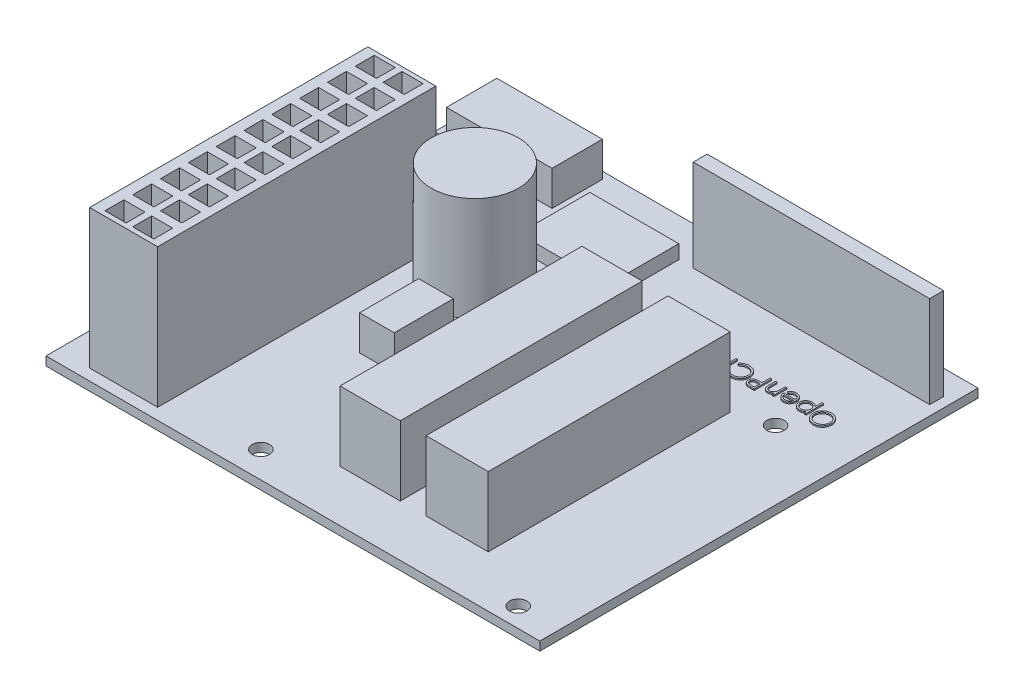
from build123d import *

# Parameters (mm, degrees)
SKETCH4_W                                   = 90.17
SKETCH4_H                                   = 80.01
PCB_DEPTH                                   = 1.6002
SKETCH18_W                                  = 12.407886853
SKETCH18_H                                  = 50.8
ATX_PLUG_DEPTH                              = 25.4
SKETCH19_W                                  = 19.276255561
SKETCH19_H                                  = 9.196610238
TERMINAL_BLOCK_PELTIER_LID_HEATER_LID_DEPTH = 6.35
SKETCH20_W                                  = 43.18
SKETCH20_H                                  = 2.54
LCD_RIBBON_HEADERS_DEPTH                    = 16.764
SKETCH21_W                                  = 9.458667613
SKETCH21_H                                  = 6.032312137
F_2_PIN_BLOCK_THERMISTOR_PLUG_DEPTH         = 6.35
SKETCH23_W                                  = 6.335830851
SKETCH23_H                                  = 10.787396263
F_3_PIN_FAN_PLUG_DEPTH                      = 6.35
SKETCH26_R                                  = 7.964425937
BOSS_EXTRUDE1_DEPTH                         = 19.05
SKETCH27_W                                  = 11.001790229
SKETCH27_H                                  = 44.181792507
SKETCH27_W_2                                = 11.351053411
BOSS_EXTRUDE2_DEPTH                         = 12.7
SKETCH28_W                                  = 16.235615253
SKETCH28_H                                  = 12.988492202
BOSS_EXTRUDE3_DEPTH                         = 2.54
SKETCH29_W                                  = 3.855958623
SKETCH29_H                                  = 3.450068241
CUT_EXTRUDE1_DEPTH                          = 12.7
BOSS_EXTRUDE4_DEPTH                         = 0.254
SKETCH36_R                                  = 0.508
BOSS_EXTRUDE8_DEPTH                         = 6.35
SKETCH25_W                                  = 2.54
SKETCH25_H                                  = 43.749294164
SKETCH25_H_2                                = 32.765794335
EXTRUSION_FOR_HEADERS_DEPTH                 = 2.54
ARDUINO_HOLES_REACH                         = 9.95
SKETCH39_R                                  = 1.5875


with BuildPart() as part:
    # Sketch4 → PCB (new body)
    with BuildSketch(Plane(origin=(0, 0, 0), x_dir=(1, 0, 0), z_dir=(0, 1, 0))):
        with Locations((-77.667503466, -6.362850239)):
            Rectangle(SKETCH4_W, SKETCH4_H)
    extrude(amount=PCB_DEPTH)

    # Sketch18 → ATX plug (add)
    with BuildSketch(Plane(origin=(0, 1.6002, 0), x_dir=(1, 0, 0), z_dir=(0, 1, 0))):
        with Locations((-110.63442677, -18.903310009)):
            Rectangle(SKETCH18_W, SKETCH18_H)
    extrude(amount=ATX_PLUG_DEPTH)

    # Sketch19 → Terminal block (peltier, lid heater, lid thermistor) (add)
    with BuildSketch(Plane(origin=(0, 1.6002, 0), x_dir=(1, 0, 0), z_dir=(0, 1, 0))):
        with Locations((-109.512826264, 27.756447705)):
            Rectangle(SKETCH19_W, SKETCH19_H)
    extrude(amount=TERMINAL_BLOCK_PELTIER_LID_HEATER_LID_DEPTH)

    # Sketch20 → LCD ribbon headers (add)
    with BuildSketch(Plane(origin=(0, 1.6002, 0), x_dir=(1, 0, 0), z_dir=(0, 1, 0))):
        with Locations((-55.96072751, 27.878210827)):
            Rectangle(SKETCH20_W, SKETCH20_H)
    extrude(amount=LCD_RIBBON_HEADERS_DEPTH)

    # Sketch21 → 2 pin block thermistor plug (add)
    with BuildSketch(Plane(origin=(0, 1.6002, 0), x_dir=(1, 0, 0), z_dir=(0, 1, 0))):
        with Locations((-114.2222126, 15.215258359)):
            Rectangle(SKETCH21_W, SKETCH21_H)
    extrude(amount=F_2_PIN_BLOCK_THERMISTOR_PLUG_DEPTH)

    # Sketch23 → 3 pin Fan plug (add)
    with BuildSketch(Plane(origin=(0, 1.6002, 0), x_dir=(1, 0, 0), z_dir=(0, 1, 0))):
        with Locations((-91.430208101, -11.865553383)):
            Rectangle(SKETCH23_W, SKETCH23_H)
    extrude(amount=F_3_PIN_FAN_PLUG_DEPTH)

    # Sketch26 → Boss-Extrude1 (add)
    with BuildSketch(Plane(origin=(0, 1.6002, 0), x_dir=(1, 0, 0), z_dir=(0, 1, 0))):
        with Locations((-95.051794494, 4.239066683)):
            Circle(SKETCH26_R)
    extrude(amount=BOSS_EXTRUDE1_DEPTH)

    # Sketch27 → Boss-Extrude2 (add)
    with BuildSketch(Plane(origin=(0, 1.6002, 0), x_dir=(1, 0, 0), z_dir=(0, 1, 0))):
        with Locations((-72.960898241, -14.883092526)):
            Rectangle(SKETCH27_W, SKETCH27_H)
        with Locations((-57.069423466, -14.883092526)):
            Rectangle(SKETCH27_W_2, SKETCH27_H)
    extrude(amount=BOSS_EXTRUDE2_DEPTH)

    # Sketch28 → Boss-Extrude3 (add)
    with BuildSketch(Plane(origin=(0, 1.6002, 0), x_dir=(1, 0, 0), z_dir=(0, 1, 0))):
        with Locations((-88.306822616, 20.113964726)):
            Rectangle(SKETCH28_W, SKETCH28_H)
    extrude(amount=BOSS_EXTRUDE3_DEPTH)

    # Sketch29 → Cut-Extrude1 (cut)
    with BuildSketch(Plane(origin=(0, 27.0002, 0), x_dir=(1, 0, 0), z_dir=(0, 1, 0))):
        with Locations((-107.913672572, 4.004968545)):
            Rectangle(SKETCH29_W, SKETCH29_H)
        with Locations((-112.993672572, 4.004968545)):
            Rectangle(SKETCH29_W, SKETCH29_H)
        with Locations((-112.993672572, -1.075031456)):
            Rectangle(SKETCH29_W, SKETCH29_H)
        with Locations((-107.913672572, -1.075031456)):
            Rectangle(SKETCH29_W, SKETCH29_H)
        with Locations((-112.993672572, -6.155031456)):
            Rectangle(SKETCH29_W, SKETCH29_H)
        with Locations((-107.913672572, -6.155031456)):
            Rectangle(SKETCH29_W, SKETCH29_H)
        with Locations((-112.993672572, -11.235031456)):
            Rectangle(SKETCH29_W, SKETCH29_H)
        with Locations((-107.913672572, -11.235031456)):
            Rectangle(SKETCH29_W, SKETCH29_H)
        with Locations((-112.993672572, -16.315031456)):
            Rectangle(SKETCH29_W, SKETCH29_H)
        with Locations((-107.913672572, -16.315031456)):
            Rectangle(SKETCH29_W, SKETCH29_H)
        with Locations((-112.993672572, -21.395031456)):
            Rectangle(SKETCH29_W, SKETCH29_H)
        with Locations((-107.913672572, -21.395031456)):
            Rectangle(SKETCH29_W, SKETCH29_H)
        with Locations((-112.993672572, -26.475031456)):
            Rectangle(SKETCH29_W, SKETCH29_H)
        with Locations((-107.913672572, -26.475031456)):
            Rectangle(SKETCH29_W, SKETCH29_H)
        with Locations((-112.993672572, -31.555031456)):
            Rectangle(SKETCH29_W, SKETCH29_H)
        with Locations((-107.913672572, -31.555031456)):
            Rectangle(SKETCH29_W, SKETCH29_H)
        with Locations((-112.993672572, -36.635031455)):
            Rectangle(SKETCH29_W, SKETCH29_H)
        with Locations((-107.913672572, -36.635031455)):
            Rectangle(SKETCH29_W, SKETCH29_H)
        with Locations((-112.993672572, -41.715031456)):
            Rectangle(SKETCH29_W, SKETCH29_H)
        with Locations((-107.913672572, -41.715031456)):
            Rectangle(SKETCH29_W, SKETCH29_H)
    extrude(amount=-CUT_EXTRUDE1_DEPTH, mode=Mode.SUBTRACT)

    # Sketch30 → Boss-Extrude4 (add)
    with BuildSketch(Plane(origin=(0, 1.6002, 0), x_dir=(-1, 0, 0), z_dir=(0, 1, 0))):
        with BuildLine():
            add(Edge.make_bspline(
                [(41.726381615, -12.7340868), (41.785171825, -12.735575856), (41.900640648, -12.738500485), (42.070344306, -12.760887958), (42.232355571, -12.799618776), (42.387994197, -12.851201624), (42.53539854, -12.920012388), (42.675678106, -13.003183915), (42.808499128, -13.10158756), (42.932071381, -13.214462645), (43.045153043, -13.337274778), (43.144780811, -13.468336882), (43.228276321, -13.60685651), (43.296843427, -13.752417406), (43.350635738, -13.904690377), (43.387755156, -14.064487222), (43.411466192, -14.230772577), (43.414238219, -14.344189804), (43.415644435, -14.401725021)],
                knots=[0, 0, 0, 0, 0.000176342, 0.00034635, 0.000512345, 0.00067546, 0.000837376, 0.000999356, 0.00116396, 0.001332355, 0.001500709, 0.001664166, 0.001825381, 0.001984993, 0.002146116, 0.00230887, 0.002476442, 0.002648971, 0.002648971, 0.002648971, 0.002648971], degree=3))
            add(Edge.make_bspline(
                [(43.415644435, -14.401725021), (43.414238425, -14.458836418), (43.411467016, -14.5714096), (43.387728196, -14.736639724), (43.350498146, -14.895471999), (43.297342962, -15.04764127), (43.229102706, -15.19330806), (43.14505123, -15.332089082), (43.04604456, -15.464029834), (42.933371202, -15.587684895), (42.810543114, -15.701075457), (42.678798515, -15.799880438), (42.541100289, -15.884901608), (42.395676482, -15.952741083), (42.244455735, -16.006962754), (42.086084627, -16.043931211), (41.921305253, -16.067777315), (41.808936557, -16.07051554), (41.75182232, -16.071907312)],
                knots=[0, 0, 0, 0, 0.000171259, 0.000337571, 0.000499706, 0.000660019, 0.000820206, 0.000981421, 0.001145895, 0.001314289, 0.001482643, 0.001646609, 0.00180761, 0.001967222, 0.002127146, 0.002288662, 0.002454344, 0.002625603, 0.002625603, 0.002625603, 0.002625603], degree=3))
            add(Edge.make_bspline(
                [(41.75182232, -16.071907312), (41.694287402, -16.070501797), (41.580870763, -16.067731152), (41.414376452, -16.043980878), (41.254467356, -16.006841267), (41.101600766, -15.95376485), (40.955691437, -15.885169219), (40.816454005, -15.801526675), (40.68444735, -15.702278768), (40.560765908, -15.589641947), (40.447600564, -15.467022039), (40.348940274, -15.335636679), (40.265278921, -15.198063515), (40.196913612, -15.053920761), (40.142789424, -14.903905238), (40.105864339, -14.747016262), (40.081973868, -14.584148282), (40.079220829, -14.47325651), (40.077823922, -14.416989444)],
                knots=[0, 0, 0, 0, 0.00017253, 0.000340102, 0.000503474, 0.000664388, 0.000824575, 0.000986335, 0.001150809, 0.001319204, 0.001487557, 0.001650632, 0.001811303, 0.001969765, 0.00212849, 0.002288769, 0.002452562, 0.00262128, 0.00262128, 0.00262128, 0.00262128], degree=3))
            add(Edge.make_bspline(
                [(40.077823922, -14.416989444), (40.078308913, -14.379222665), (40.079272776, -14.304165553), (40.090876669, -14.192707995), (40.107714783, -14.083042898), (40.131846518, -13.975482109), (40.16340753, -13.87028893), (40.200647584, -13.766737881), (40.246131586, -13.66587836), (40.297549031, -13.567232569), (40.354936529, -13.472338255), (40.418323816, -13.382640347), (40.485484471, -13.297386157), (40.559111264, -13.218784947), (40.636777611, -13.14455013), (40.719743425, -13.075822522), (40.807502461, -13.011982388), (40.900432334, -12.954451079), (40.996243198, -12.902418149), (41.095009989, -12.857766899), (41.195391308, -12.819443686), (41.29785731, -12.788382366), (41.402135896, -12.763860448), (41.508454658, -12.747162348), (41.616728894, -12.73552886), (41.689673448, -12.734569554), (41.726381615, -12.7340868)],
                knots=[0, 0, 0, 0, 0.000113256, 0.000225083, 0.000335817, 0.000445988, 0.000555461, 0.000665116, 0.000775867, 0.0008871, 0.000998686, 0.001108262, 0.001216432, 0.001323994, 0.001431064, 0.001538557, 0.001646949, 0.001756368, 0.001866213, 0.001973803, 0.002081296, 0.002188332, 0.002294783, 0.002402377, 0.00251104, 0.002621117, 0.002621117, 0.002621117, 0.002621117], degree=3))
        make_face()
        with BuildLine():
            add(Edge.make_bspline(
                [(41.740374002, -13.059727825), (41.710243585, -13.060095118), (41.650270798, -13.060826194), (41.561112683, -13.070456164), (41.473127143, -13.084181135), (41.386296008, -13.103758657), (41.300982588, -13.130432334), (41.216391661, -13.161130872), (41.133294605, -13.19852429), (41.051965748, -13.240772386), (40.973121358, -13.287534621), (40.898724122, -13.339216153), (40.828581438, -13.394604984), (40.762865046, -13.453830379), (40.701767911, -13.517193947), (40.644087504, -13.583735085), (40.592135812, -13.655355729), (40.544523895, -13.730113741), (40.501917355, -13.807911747), (40.464030211, -13.887930694), (40.433038575, -13.970823309), (40.407763419, -14.055690295), (40.386808591, -14.142397241), (40.373533531, -14.231601904), (40.363797748, -14.322856041), (40.36310846, -14.384525294), (40.36275982, -14.415717408)],
                knots=[0, 0, 0, 0, 9.035e-05, 0.000179837, 0.000268716, 0.000357433, 0.000446559, 0.000536708, 0.000627246, 0.000719699, 0.000811541, 0.000902048, 0.000991247, 0.001079509, 0.001167217, 0.001255174, 0.001343459, 0.001432386, 0.001520911, 0.0016094, 0.001697761, 0.001786094, 0.001874954, 0.00196509, 0.002056475, 0.002150004, 0.002150004, 0.002150004, 0.002150004], degree=3))
            add(Edge.make_bspline(
                [(40.36275982, -14.415717408), (40.363916302, -14.461584566), (40.366191459, -14.551819454), (40.386110112, -14.684051985), (40.416791475, -14.811132073), (40.462019229, -14.932364376), (40.518580143, -15.048790976), (40.588454537, -15.159379042), (40.671239564, -15.264158464), (40.765277192, -15.362397744), (40.868077076, -15.452065009), (40.977236052, -15.530771815), (41.091584682, -15.597365399), (41.211421159, -15.651617143), (41.336105712, -15.694606405), (41.466441776, -15.724069164), (41.601561121, -15.743459755), (41.69366393, -15.745321898), (41.740374002, -15.746266287)],
                knots=[0, 0, 0, 0, 0.000137527, 0.000270558, 0.000400289, 0.000529072, 0.000657927, 0.000787976, 0.000920685, 0.001057889, 0.001195382, 0.001329354, 0.001461022, 0.001591668, 0.001723409, 0.001855936, 0.001992028, 0.002132069, 0.002132069, 0.002132069, 0.002132069], degree=3))
            add(Edge.make_bspline(
                [(41.740374002, -15.746266287), (41.771769765, -15.745834936), (41.83403699, -15.744979439), (41.926652214, -15.736362782), (42.017598921, -15.722545301), (42.106749546, -15.702651063), (42.194002911, -15.677752526), (42.279723196, -15.648172658), (42.36299736, -15.611268995), (42.444875927, -15.570494782), (42.52324966, -15.524012639), (42.59806675, -15.474085174), (42.667441389, -15.418777926), (42.733108618, -15.360432481), (42.794456593, -15.297872419), (42.851070457, -15.231179075), (42.902759577, -15.159931479), (42.950353414, -15.085286861), (42.992810659, -15.007275975), (43.029803128, -14.92696691), (43.061186747, -14.844557418), (43.086521891, -14.759928635), (43.106375131, -14.673241293), (43.120054773, -14.584379323), (43.129623714, -14.49352049), (43.130344962, -14.432067135), (43.130708538, -14.401089003)],
                knots=[0, 0, 0, 0, 9.4165e-05, 0.000186757, 0.000278778, 0.000369977, 0.000460573, 0.00055089, 0.000641754, 0.000733627, 0.000825145, 0.000914934, 0.00100324, 0.001091077, 0.00117833, 0.001265874, 0.00135327, 0.001442197, 0.00153128, 0.001619501, 0.001707267, 0.0017956, 0.001884317, 0.001973824, 0.00206521, 0.002158103, 0.002158103, 0.002158103, 0.002158103], degree=3))
            add(Edge.make_bspline(
                [(43.130708538, -14.401089003), (43.130344671, -14.370322796), (43.129622874, -14.309292356), (43.120059344, -14.219067185), (43.106360679, -14.130844629), (43.086618794, -14.044971036), (43.061173297, -13.961424517), (43.029797647, -13.880283539), (42.992799554, -13.801245819), (42.950337808, -13.724506706), (42.902607739, -13.650869623), (42.850452247, -13.580473149), (42.792970824, -13.514639305), (42.731805787, -13.451742832), (42.665429341, -13.393125175), (42.59414216, -13.338766889), (42.518809681, -13.287356133), (42.439047118, -13.240977944), (42.356729388, -13.19814789), (42.272261726, -13.161453052), (42.186601043, -13.130272629), (42.09996517, -13.103677954), (42.011624897, -13.084257812), (41.922177137, -13.070443796), (41.831745646, -13.060829545), (41.770927868, -13.060096231), (41.740374002, -13.059727825)],
                knots=[0, 0, 0, 0, 9.2258e-05, 0.00018301, 0.000271889, 0.000359986, 0.000447102, 0.00053368, 0.000620747, 0.000708715, 0.000796571, 0.000883833, 0.000971308, 0.00105856, 0.001146873, 0.001236684, 0.001327357, 0.001420293, 0.001513311, 0.001605595, 0.001696341, 0.001786684, 0.001877263, 0.001967398, 0.00205815, 0.002149772, 0.002149772, 0.002149772, 0.002149772], degree=3))
        make_face(mode=Mode.SUBTRACT)
        with BuildLine():
            Line((43.98551623, -13.670304748), (44.270452127, -13.670304748))
            Line((44.270452127, -13.670304748), (44.270452127, -14.099616647))
            add(Edge.make_bspline(
                [(44.270452127, -14.099616647), (44.300712131, -14.060665989), (44.359516392, -13.984973179), (44.460866841, -13.887010705), (44.567843303, -13.804392394), (44.683198685, -13.739638239), (44.805140175, -13.690815074), (44.933167349, -13.65472943), (45.0683668, -13.633464664), (45.160801439, -13.630905014), (45.207942111, -13.62959962)],
                knots=[0, 0, 0, 0, 0.000147809, 0.000287238, 0.000421569, 0.000552289, 0.000682679, 0.000814774, 0.000950605, 0.001091975, 0.001091975, 0.001091975, 0.001091975], degree=3))
            add(Edge.make_bspline(
                [(45.207942111, -13.62959962), (45.24911878, -13.630790861), (45.330506629, -13.633145411), (45.450306843, -13.649086682), (45.565673084, -13.676407731), (45.675952676, -13.715778562), (45.782327028, -13.764451738), (45.883221361, -13.825880763), (45.98020723, -13.897006379), (46.070845487, -13.97885983), (46.154594156, -14.067422615), (46.227026049, -14.162692848), (46.289502705, -14.26153748), (46.340003617, -14.365488878), (46.379562618, -14.473728465), (46.407697361, -14.586693551), (46.42444108, -14.703965297), (46.426687576, -14.783705622), (46.427823922, -14.824040726)],
                knots=[0, 0, 0, 0, 0.00012352, 0.000244144, 0.000361849, 0.000478519, 0.000594903, 0.00071216, 0.000832245, 0.000955207, 0.001078051, 0.001197373, 0.001313669, 0.001428302, 0.001543391, 0.001658775, 0.001776965, 0.001897944, 0.001897944, 0.001897944, 0.001897944], degree=3))
            add(Edge.make_bspline(
                [(46.427823922, -14.824040726), (46.426712232, -14.865227106), (46.424519818, -14.94645259), (46.407515419, -15.065730172), (46.380340255, -15.180472289), (46.341280332, -15.290488093), (46.290805553, -15.395701833), (46.229387845, -15.496037636), (46.156919407, -15.591463352), (46.074096241, -15.680683483), (45.984241077, -15.762870002), (45.888195069, -15.834750251), (45.787448758, -15.895112785), (45.682517578, -15.945534469), (45.572503249, -15.983536665), (45.457919061, -16.010948527), (45.3388274, -16.027852677), (45.257818497, -16.03007712), (45.216846358, -16.031202184)],
                knots=[0, 0, 0, 0, 0.00012352, 0.0002436, 0.000360686, 0.000476757, 0.000593108, 0.000710151, 0.000829088, 0.000951964, 0.00107488, 0.001193943, 0.0013112, 0.001426703, 0.001542563, 0.001659649, 0.001779729, 0.001902613, 0.001902613, 0.001902613, 0.001902613], degree=3))
            add(Edge.make_bspline(
                [(45.216846358, -16.031202184), (45.170738489, -16.030027609), (45.079661931, -16.027707477), (44.946495472, -16.00419487), (44.818337185, -15.969054935), (44.696606937, -15.917620848), (44.580340422, -15.852074773), (44.470195312, -15.772146229), (44.365586543, -15.678002377), (44.302622885, -15.606581372), (44.270452127, -15.570089404)],
                knots=[0, 0, 0, 0, 0.000138193, 0.000272972, 0.000404455, 0.00053616, 0.0006683, 0.000804048, 0.000943651, 0.0010895, 0.0010895, 0.0010895, 0.0010895], degree=3))
            Line((44.270452127, -15.570089404), (44.270452127, -16.845304748))
            Line((44.270452127, -16.845304748), (43.98551623, -16.845304748))
            Line((43.98551623, -16.845304748), (43.98551623, -13.670304748))
        make_face()
        with BuildLine():
            add(Edge.make_bspline(
                [(45.205398041, -13.914535517), (45.173122295, -13.915116323), (45.10957967, -13.91625978), (45.0164413, -13.92984329), (44.926729019, -13.949562527), (44.841346963, -13.979418322), (44.759476761, -14.016065817), (44.681748983, -14.061860213), (44.60821819, -14.115973104), (44.539069384, -14.177367937), (44.476600539, -14.245017833), (44.421298454, -14.317215346), (44.374846113, -14.393869044), (44.336290709, -14.474264908), (44.306950731, -14.559033131), (44.286126614, -14.647690936), (44.273036222, -14.74033536), (44.271322687, -14.803432595), (44.270452127, -14.835489043)],
                knots=[0, 0, 0, 0, 9.675e-05, 0.000190476, 0.000281815, 0.000371923, 0.000461301, 0.000550529, 0.000641994, 0.000734796, 0.000827511, 0.000917828, 0.001007163, 0.001095923, 0.001184829, 0.001275693, 0.001368789, 0.00146493, 0.00146493, 0.00146493, 0.00146493], degree=3))
            add(Edge.make_bspline(
                [(44.270452127, -14.835489043), (44.271895261, -14.877569688), (44.274722482, -14.960009235), (44.297707095, -15.080463403), (44.33511337, -15.194447405), (44.388207274, -15.301001346), (44.455288288, -15.398957203), (44.536113044, -15.486669396), (44.629950216, -15.563586575), (44.73523974, -15.628375855), (44.848108387, -15.680979316), (44.96584275, -15.718638635), (45.086823749, -15.741836299), (45.168619296, -15.744781628), (45.209850164, -15.746266287)],
                knots=[0, 0, 0, 0, 0.000126163, 0.000247163, 0.000366431, 0.000485041, 0.000603063, 0.000721446, 0.000841645, 0.000965897, 0.001091387, 0.001214284, 0.00133591, 0.001459533, 0.001459533, 0.001459533, 0.001459533], degree=3))
            add(Edge.make_bspline(
                [(45.209850164, -15.746266287), (45.250250468, -15.744854431), (45.330437808, -15.74205215), (45.448509818, -15.717796794), (45.563254897, -15.680744522), (45.672275482, -15.626715495), (45.774622503, -15.560503086), (45.867043627, -15.481073627), (45.947785613, -15.38900775), (46.016605421, -15.286492894), (46.072060411, -15.17656951), (46.1137257, -15.062830679), (46.137772763, -14.945677331), (46.141180707, -14.866757977), (46.142888025, -14.827220814)],
                knots=[0, 0, 0, 0, 0.000121084, 0.00024033, 0.000360202, 0.000481946, 0.000604197, 0.000725061, 0.00084628, 0.000970466, 0.001094482, 0.001214788, 0.001332911, 0.001451499, 0.001451499, 0.001451499, 0.001451499], degree=3))
            add(Edge.make_bspline(
                [(46.142888025, -14.827220814), (46.141568373, -14.787438074), (46.138939352, -14.708182541), (46.113043111, -14.591376193), (46.074126702, -14.477177815), (46.017376705, -14.368755602), (45.950065554, -14.266453399), (45.868652206, -14.176143808), (45.777378942, -14.097067555), (45.675153772, -14.031739291), (45.565443529, -13.979773163), (45.449950713, -13.941778719), (45.329261159, -13.918942532), (45.24704893, -13.916017444), (45.205398041, -13.914535517)],
                knots=[0, 0, 0, 0, 0.00011918, 0.000237431, 0.000357313, 0.000480195, 0.000603499, 0.000723767, 0.000843733, 0.000964759, 0.001086524, 0.001207, 0.001328626, 0.001453519, 0.001453519, 0.001453519, 0.001453519], degree=3))
        make_face(mode=Mode.SUBTRACT)
        with BuildLine():
            Line((48.901932496, -15.257804748), (49.155067512, -15.390732433))
            add(Edge.make_bspline(
                [(49.155067512, -15.390732433), (49.134895743, -15.426513169), (49.09564947, -15.496128312), (49.028157363, -15.591770071), (48.957407411, -15.677810499), (48.880205955, -15.751950971), (48.798862746, -15.816586156), (48.712926695, -15.873135469), (48.62195041, -15.921321555), (48.525929588, -15.961918491), (48.424057853, -15.993132818), (48.316088334, -16.015180218), (48.201814192, -16.028808469), (48.123485872, -16.030391561), (48.083377808, -16.031202184)],
                knots=[0, 0, 0, 0, 0.000123153, 0.000239607, 0.000350682, 0.000456834, 0.000560038, 0.000661999, 0.000764997, 0.000868472, 0.000974292, 0.00108406, 0.001198688, 0.001318978, 0.001318978, 0.001318978, 0.001318978], degree=3))
            add(Edge.make_bspline(
                [(48.083377808, -16.031202184), (48.038799015, -16.030161532), (47.951838702, -16.028131522), (47.825256217, -16.010630501), (47.706076316, -15.982080575), (47.5943057, -15.942197548), (47.490218085, -15.890102761), (47.393606595, -15.826639517), (47.303963168, -15.752133829), (47.224112635, -15.665940341), (47.152227113, -15.57370028), (47.088794405, -15.477583156), (47.035765164, -15.377830802), (46.992628153, -15.275078255), (46.957789455, -15.169973152), (46.93350823, -15.061559178), (46.919511245, -14.950129755), (46.917366355, -14.8747486), (46.916285461, -14.836761078)],
                knots=[0, 0, 0, 0, 0.000133686, 0.000260783, 0.000382495, 0.000500791, 0.000615988, 0.000730827, 0.00084687, 0.000964755, 0.001082568, 0.001197407, 0.001309796, 0.001420953, 0.001531373, 0.001641544, 0.001753723, 0.001867684, 0.001867684, 0.001867684, 0.001867684], degree=3))
            add(Edge.make_bspline(
                [(46.916285461, -14.836761078), (46.917246253, -14.801115054), (46.919150417, -14.73046934), (46.931152631, -14.625907025), (46.952423583, -14.524281214), (46.981612105, -14.425507465), (47.019305021, -14.329751158), (47.065417106, -14.236954014), (47.120020192, -14.14721478), (47.162177546, -14.090606223), (47.183412865, -14.062091607)],
                knots=[0, 0, 0, 0, 0.000106944, 0.000211948, 0.00031523, 0.000418063, 0.00052058, 0.000623546, 0.000728589, 0.000835205, 0.000835205, 0.000835205, 0.000835205], degree=3))
            add(Edge.make_bspline(
                [(47.183412865, -14.062091607), (47.212176262, -14.027739132), (47.268791907, -13.960122381), (47.364546601, -13.871278329), (47.468233207, -13.796852904), (47.578552325, -13.735160716), (47.696786127, -13.688285337), (47.821345269, -13.653353458), (47.953648051, -13.63377912), (48.04409493, -13.631014299), (48.090374002, -13.62959962)],
                knots=[0, 0, 0, 0, 0.000134322, 0.000264389, 0.000390598, 0.000516434, 0.000642571, 0.000771262, 0.000903757, 0.001042585, 0.001042585, 0.001042585, 0.001042585], degree=3))
            add(Edge.make_bspline(
                [(48.090374002, -13.62959962), (48.137951473, -13.630827936), (48.231287625, -13.633237611), (48.367388191, -13.655577214), (48.496166841, -13.69100346), (48.617572042, -13.741035827), (48.731616101, -13.805587706), (48.837557732, -13.885544948), (48.937208747, -13.978452784), (48.995182958, -14.049902267), (49.024683898, -14.086260277)],
                knots=[0, 0, 0, 0, 0.00014264, 0.000279826, 0.000412535, 0.000542577, 0.000672743, 0.000804526, 0.000939956, 0.001080274, 0.001080274, 0.001080274, 0.001080274], degree=3))
            add(Edge.make_bspline(
                [(49.024683898, -14.086260277), (49.044756192, -14.11365924), (49.084767173, -14.168274791), (49.134884185, -14.257330055), (49.178388394, -14.350503237), (49.213161865, -14.449300435), (49.241319127, -14.552551054), (49.26169067, -14.660993219), (49.273637395, -14.774594639), (49.275985714, -14.851998014), (49.277182897, -14.891458594)],
                knots=[0, 0, 0, 0, 0.000101812, 0.000202947, 0.000305961, 0.000409966, 0.000516734, 0.000626756, 0.00074061, 0.000859019, 0.000859019, 0.000859019, 0.000859019], degree=3))
            Line((49.277182897, -14.891458594), (47.201221358, -14.891458594))
            add(Edge.make_bspline(
                [(47.201221358, -14.891458594), (47.202618001, -14.92202973), (47.205364443, -14.982146635), (47.218168894, -15.070112988), (47.238351711, -15.153908805), (47.266717217, -15.232905565), (47.301067856, -15.308135038), (47.343146327, -15.379039171), (47.393347208, -15.445295008), (47.449341236, -15.507495197), (47.511668387, -15.56288603), (47.577239164, -15.612462999), (47.646992613, -15.654015219), (47.720378731, -15.68774269), (47.797278851, -15.714146277), (47.877717199, -15.732169228), (47.96153549, -15.744240675), (48.018672549, -15.745582943), (48.047760821, -15.746266287)],
                knots=[0, 0, 0, 0, 9.1765e-05, 0.000180453, 0.000266221, 0.000349905, 0.000431862, 0.000513997, 0.00059668, 0.000680877, 0.000764648, 0.00084644, 0.000927156, 0.001007692, 0.001088346, 0.00117058, 0.001254681, 0.001341899, 0.001341899, 0.001341899, 0.001341899], degree=3))
            add(Edge.make_bspline(
                [(48.047760821, -15.746266287), (48.076200791, -15.745714692), (48.132631146, -15.744620224), (48.216669638, -15.733977704), (48.29934621, -15.716768954), (48.380318673, -15.693283035), (48.457943655, -15.664638319), (48.529830689, -15.630073584), (48.595943456, -15.591837742), (48.657735276, -15.54810468), (48.717671106, -15.494575824), (48.777127504, -15.427777706), (48.840878468, -15.348776877), (48.880783313, -15.289317595), (48.901932496, -15.257804748)],
                knots=[0, 0, 0, 0, 8.5286e-05, 0.000169223, 0.00025367, 0.000338413, 0.000421935, 0.00050159, 0.000577404, 0.000650822, 0.000728307, 0.000817895, 0.000918814, 0.001032611, 0.001032611, 0.001032611, 0.001032611], degree=3))
        make_face()
        with BuildLine():
            add(Edge.make_bspline(
                [(48.992246999, -14.606522697), (48.981817918, -14.568728519), (48.961745295, -14.495986891), (48.919802307, -14.395256941), (48.872565981, -14.305732916), (48.816666267, -14.228099963), (48.753330709, -14.15915392), (48.680174008, -14.098902774), (48.598135733, -14.045002658), (48.507639941, -13.999507176), (48.41180775, -13.960781376), (48.311472133, -13.934814307), (48.209093997, -13.917025651), (48.139847895, -13.915369109), (48.105002408, -13.914535517)],
                knots=[0, 0, 0, 0, 0.000117514, 0.000226176, 0.00032663, 0.000420529, 0.000512345, 0.000606726, 0.000704101, 0.000806217, 0.000910151, 0.001013517, 0.001116615, 0.001221046, 0.001221046, 0.001221046, 0.001221046], degree=3))
            add(Edge.make_bspline(
                [(48.105002408, -13.914535517), (48.076563989, -13.915090391), (48.020347213, -13.916187259), (47.937524101, -13.926592305), (47.857986088, -13.943791593), (47.781146292, -13.967345518), (47.708011647, -13.998740464), (47.637077821, -14.035555248), (47.570148462, -14.080496542), (47.528291715, -14.114749218), (47.507145837, -14.132053546)],
                knots=[0, 0, 0, 0, 8.5286e-05, 0.000168592, 0.000249928, 0.000329188, 0.000409278, 0.000488369, 0.000568631, 0.000650579, 0.000650579, 0.000650579, 0.000650579], degree=3))
            add(Edge.make_bspline(
                [(47.507145837, -14.132053546), (47.492002646, -14.145746247), (47.461356517, -14.173456936), (47.420407615, -14.221199145), (47.381200472, -14.272680919), (47.34551923, -14.329871853), (47.312791705, -14.392120703), (47.282166583, -14.458902415), (47.254601766, -14.530723754), (47.239093152, -14.580773039), (47.231114187, -14.606522697)],
                knots=[0, 0, 0, 0, 6.119e-05, 0.000123834, 0.000188326, 0.000255205, 0.000325765, 0.000399195, 0.000475498, 0.000556355, 0.000556355, 0.000556355, 0.000556355], degree=3))
            Line((47.231114187, -14.606522697), (48.992246999, -14.606522697))
        make_face(mode=Mode.SUBTRACT)
        with BuildLine():
            Line((49.847054691, -13.670304748), (50.131990589, -13.670304748))
            Line((50.131990589, -13.670304748), (50.131990589, -14.088804348))
            add(Edge.make_bspline(
                [(50.131990589, -14.088804348), (50.162414015, -14.05084702), (50.221451735, -13.977189503), (50.319771809, -13.880378696), (50.42367949, -13.800599813), (50.53253845, -13.737005657), (50.646496466, -13.689066218), (50.764858897, -13.654444266), (50.88833438, -13.633684457), (50.972303548, -13.630971891), (51.014783057, -13.62959962)],
                knots=[0, 0, 0, 0, 0.000145848, 0.000283023, 0.000412777, 0.000537898, 0.000660162, 0.000782735, 0.000907163, 0.001034558, 0.001034558, 0.001034558, 0.001034558], degree=3))
            add(Edge.make_bspline(
                [(51.014783057, -13.62959962), (51.057718703, -13.631182762), (51.141754121, -13.634281352), (51.264107791, -13.65878935), (51.378383655, -13.700649688), (51.484174252, -13.757992067), (51.579539653, -13.829299368), (51.663291482, -13.912373498), (51.732563857, -14.007928374), (51.779007179, -14.096577237), (51.809601159, -14.175216357), (51.828861922, -14.242568766), (51.845218599, -14.317605946), (51.859398827, -14.400101145), (51.868993779, -14.49063236), (51.876561429, -14.588828481), (51.881984959, -14.694657699), (51.882200139, -14.767851997), (51.882311102, -14.805596215)],
                knots=[0, 0, 0, 0, 0.000128741, 0.000251978, 0.000372501, 0.000492599, 0.000611662, 0.000728592, 0.000845121, 0.000964321, 0.001027748, 0.001097989, 0.001174219, 0.001258077, 0.001348963, 0.001447206, 0.001553543, 0.001666761, 0.001666761, 0.001666761, 0.001666761], degree=3))
            Line((51.882311102, -14.805596215), (51.882311102, -15.990497056))
            Line((51.882311102, -15.990497056), (51.597375204, -15.990497056))
            Line((51.597375204, -15.990497056), (51.597375204, -14.899090806))
            add(Edge.make_bspline(
                [(51.597375204, -14.899090806), (51.597199937, -14.867501874), (51.596864681, -14.807077623), (51.595807272, -14.720564294), (51.593258376, -14.642108613), (51.589676693, -14.571898144), (51.584434286, -14.510000306), (51.578970899, -14.456289034), (51.572289813, -14.41083252), (51.566336313, -14.383468481), (51.56366627, -14.371196175)],
                knots=[0, 0, 0, 0, 9.4769e-05, 0.000181277, 0.000259548, 0.000330249, 0.000392152, 0.000445883, 0.000492208, 0.000529878, 0.000529878, 0.000529878, 0.000529878], degree=3))
            add(Edge.make_bspline(
                [(51.56366627, -14.371196175), (51.554027395, -14.335172457), (51.535475543, -14.265837946), (51.489634001, -14.171790497), (51.431745423, -14.091782141), (51.361080945, -14.026307544), (51.278323141, -13.97535257), (51.183701661, -13.939997626), (51.078129609, -13.917884867), (51.00387599, -13.915683112), (50.965173682, -13.914535517)],
                knots=[0, 0, 0, 0, 0.000111666, 0.000214922, 0.000311858, 0.000406371, 0.000502038, 0.000601493, 0.000708018, 0.000823984, 0.000823984, 0.000823984, 0.000823984], degree=3))
            add(Edge.make_bspline(
                [(50.965173682, -13.914535517), (50.942252283, -13.914967322), (50.896891427, -13.915821851), (50.82962681, -13.924395529), (50.76438131, -13.938418556), (50.70050012, -13.957349392), (50.639260908, -13.983350164), (50.578696158, -14.01285895), (50.52108645, -14.049641971), (50.465203369, -14.090636321), (50.413212464, -14.136065316), (50.364836043, -14.184002836), (50.321712268, -14.235052848), (50.282642827, -14.2883928), (50.24891683, -14.344755253), (50.219477243, -14.403596445), (50.194498435, -14.464993823), (50.182086278, -14.507606914), (50.175875805, -14.528928546)],
                knots=[0, 0, 0, 0, 6.8737e-05, 0.000136029, 0.000203016, 0.000268809, 0.000335543, 0.000402385, 0.000470679, 0.000540262, 0.000610145, 0.000677605, 0.000744384, 0.000810411, 0.000875747, 0.000941168, 0.001007661, 0.001074249, 0.001074249, 0.001074249, 0.001074249], degree=3))
            add(Edge.make_bspline(
                [(50.175875805, -14.528928546), (50.172301981, -14.544581481), (50.164521953, -14.578657099), (50.156118926, -14.634577394), (50.148492054, -14.699265729), (50.142108527, -14.772646616), (50.138202899, -14.854976974), (50.133944411, -14.945905199), (50.132394048, -15.045793863), (50.132128841, -15.11533697), (50.131990589, -15.151589804)],
                knots=[0, 0, 0, 0, 4.8153e-05, 0.000104826, 0.000169516, 0.000243568, 0.000325735, 0.000416765, 0.000516638, 0.000625399, 0.000625399, 0.000625399, 0.000625399], degree=3))
            Line((50.131990589, -15.151589804), (50.131990589, -15.990497056))
            Line((50.131990589, -15.990497056), (49.847054691, -15.990497056))
            Line((49.847054691, -15.990497056), (49.847054691, -13.670304748))
        make_face()
        with BuildLine():
            Line((52.615003409, -12.815497056), (53.237664667, -12.815497056))
            add(Edge.make_bspline(
                [(53.237664667, -12.815497056), (53.280491704, -12.815544133), (53.362550207, -12.815634335), (53.480220293, -12.818369141), (53.58709055, -12.822021926), (53.682930538, -12.8270855), (53.768035142, -12.83306955), (53.842019263, -12.841462471), (53.905464432, -12.850225739), (53.943479569, -12.859135158), (53.960816711, -12.863198378)],
                knots=[0, 0, 0, 0, 0.000128477, 0.000246168, 0.000353087, 0.00044926, 0.000534089, 0.000608961, 0.000672646, 0.000726041, 0.000726041, 0.000726041, 0.000726041], degree=3))
            add(Edge.make_bspline(
                [(53.960816711, -12.863198378), (53.982763702, -12.869205433), (54.026140531, -12.881077993), (54.08864362, -12.904857585), (54.148110323, -12.933053549), (54.204744665, -12.965188123), (54.257850698, -13.002640028), (54.308220749, -13.043891095), (54.355410303, -13.089893732), (54.399153994, -13.140131975), (54.439326632, -13.193762451), (54.473915701, -13.25158576), (54.502878257, -13.312628585), (54.527718796, -13.376848467), (54.54559718, -13.444784689), (54.559065439, -13.515965207), (54.567614016, -13.59038239), (54.568432768, -13.641236699), (54.568849563, -13.66712466)],
                knots=[0, 0, 0, 0, 6.8232e-05, 0.000134856, 0.000200292, 0.000265532, 0.000329934, 0.000395001, 0.000460668, 0.00052738, 0.000594672, 0.000661426, 0.000729131, 0.00079717, 0.00086768, 0.00093953, 0.001014402, 0.001092038, 0.001092038, 0.001092038, 0.001092038], degree=3))
            add(Edge.make_bspline(
                [(54.568849563, -13.66712466), (54.568467271, -13.693230215), (54.56771929, -13.744307496), (54.558741945, -13.819031382), (54.546649557, -13.890440207), (54.528055803, -13.958375637), (54.503702942, -14.022434229), (54.475135151, -14.083594918), (54.440678663, -14.140817192), (54.401086567, -14.194308792), (54.357043335, -14.244119926), (54.308735313, -14.289889633), (54.256357526, -14.331349997), (54.200076435, -14.368593966), (54.139343357, -14.400757876), (54.075079404, -14.429566289), (54.006725993, -14.453760751), (53.959425284, -14.466488021), (53.935376006, -14.472958995)],
                knots=[0, 0, 0, 0, 7.8272e-05, 0.000153144, 0.000225504, 0.0002954, 0.000364034, 0.000430891, 0.000497646, 0.000564048, 0.000630282, 0.000696867, 0.000763418, 0.000830451, 0.000899029, 0.000969354, 0.001041572, 0.001116269, 0.001116269, 0.001116269, 0.001116269], degree=3))
            add(Edge.make_bspline(
                [(53.935376006, -14.472958995), (53.915484781, -14.477188985), (53.871892006, -14.486459254), (53.800098251, -14.496808354), (53.716509223, -14.505641749), (53.621239011, -14.512264924), (53.514373133, -14.517934901), (53.395853779, -14.522441672), (53.265448294, -14.524918039), (53.174487951, -14.525045758), (53.1269976, -14.525112441)],
                knots=[0, 0, 0, 0, 6.0995e-05, 0.000133673, 0.000217466, 0.000313125, 0.000420129, 0.000538512, 0.000668921, 0.00081139, 0.00081139, 0.00081139, 0.00081139], degree=3))
            Line((53.1269976, -14.525112441), (52.899939307, -14.525112441))
            Line((52.899939307, -14.525112441), (52.899939307, -15.990497056))
            Line((52.899939307, -15.990497056), (52.615003409, -15.990497056))
            Line((52.615003409, -15.990497056), (52.615003409, -12.815497056))
        make_face()
        with BuildLine():
            Line((52.899939307, -13.141138082), (52.899939307, -14.199471415))
            Line((52.899939307, -14.199471415), (53.455818714, -14.206467609))
            add(Edge.make_bspline(
                [(53.455818714, -14.206467609), (53.482960361, -14.206481636), (53.535356751, -14.206508717), (53.611045325, -14.20289355), (53.681266607, -14.198720209), (53.7458049, -14.192609764), (53.804689298, -14.183972624), (53.858017985, -14.175253404), (53.905377449, -14.162639254), (53.960803153, -14.145654756), (54.022564475, -14.116687311), (54.089754323, -14.07464134), (54.146696212, -14.021046697), (54.195970667, -13.960787164), (54.235073856, -13.893750097), (54.263699649, -13.822023276), (54.280519128, -13.746342298), (54.282774461, -13.694555201), (54.283913666, -13.668396695)],
                knots=[0, 0, 0, 0, 8.1413e-05, 0.000157166, 0.000227269, 0.000292454, 0.000351549, 0.000405819, 0.000454411, 0.000498462, 0.000579576, 0.00065826, 0.000735229, 0.000813005, 0.000891109, 0.000967051, 0.001043901, 0.00112234, 0.00112234, 0.00112234, 0.00112234], degree=3))
            add(Edge.make_bspline(
                [(54.283913666, -13.668396695), (54.282768265, -13.642871044), (54.28049135, -13.592129208), (54.263567817, -13.517762761), (54.235129511, -13.4467918), (54.195708172, -13.380594787), (54.147864432, -13.320552086), (54.092257171, -13.268393978), (54.029017284, -13.226464291), (53.970190674, -13.199401243), (53.91793817, -13.182877386), (53.872552035, -13.171315995), (53.821306923, -13.162085266), (53.764186152, -13.15461086), (53.701632452, -13.148212363), (53.63310841, -13.143870798), (53.558873605, -13.141329477), (53.507338301, -13.141203425), (53.480623401, -13.141138082)],
                knots=[0, 0, 0, 0, 7.6536e-05, 0.000152145, 0.000227496, 0.000305051, 0.000382429, 0.000457133, 0.000532809, 0.00060908, 0.000650514, 0.0006971, 0.000749494, 0.000806611, 0.000869897, 0.000938097, 0.001012554, 0.001092695, 0.001092695, 0.001092695, 0.001092695], degree=3))
            Line((53.480623401, -13.141138082), (52.899939307, -13.141138082))
        make_face(mode=Mode.SUBTRACT)
        with BuildLine():
            Line((58.150900845, -13.398089203), (57.901581935, -13.588894492))
            add(Edge.make_bspline(
                [(57.901581935, -13.588894492), (57.883796593, -13.567698219), (57.848465695, -13.525591446), (57.791624847, -13.466464287), (57.732386928, -13.411069372), (57.670774583, -13.359142809), (57.60567881, -13.312500458), (57.538676514, -13.268711671), (57.468646859, -13.229461652), (57.371807785, -13.181870229), (57.245127237, -13.132207645), (57.085656205, -13.090566857), (56.919185422, -13.064059076), (56.805613314, -13.061188113), (56.747845957, -13.059727825)],
                knots=[0, 0, 0, 0, 8.299e-05, 0.000164861, 0.000245858, 0.000326233, 0.000406381, 0.000485944, 0.000566254, 0.000647036, 0.000809554, 0.000973391, 0.001140702, 0.001313896, 0.001313896, 0.001313896, 0.001313896], degree=3))
            add(Edge.make_bspline(
                [(56.747845957, -13.059727825), (56.716020393, -13.060094277), (56.652664636, -13.060823779), (56.558640663, -13.070447771), (56.466372395, -13.083974369), (56.375919851, -13.104045198), (56.287398167, -13.12942036), (56.200228631, -13.159741985), (56.115673301, -13.197256733), (56.032562471, -13.238720654), (55.952934187, -13.285554122), (55.877591393, -13.336638377), (55.806808879, -13.391401771), (55.740530653, -13.450049561), (55.678688957, -13.512317625), (55.621731896, -13.578869563), (55.56985656, -13.649492607), (55.522034687, -13.723255483), (55.479205993, -13.799943337), (55.443346745, -13.879840008), (55.411592099, -13.961577302), (55.386464929, -14.046078712), (55.36657626, -14.13274965), (55.352853308, -14.221822721), (55.343338767, -14.313111845), (55.342612892, -14.374987436), (55.342246999, -14.406177144)],
                knots=[0, 0, 0, 0, 9.5437e-05, 0.000189987, 0.000283265, 0.000375086, 0.000467691, 0.000559419, 0.000651703, 0.000744998, 0.000837935, 0.000928607, 0.001017915, 0.001106228, 0.001193927, 0.001280987, 0.00136876, 0.001456615, 0.001544584, 0.001631962, 0.001719133, 0.001807466, 0.001896183, 0.00198569, 0.002077709, 0.002171238, 0.002171238, 0.002171238, 0.002171238], degree=3))
            add(Edge.make_bspline(
                [(55.342246999, -14.406177144), (55.343391649, -14.453104841), (55.345639018, -14.545241151), (55.365640007, -14.680197347), (55.396033911, -14.809483958), (55.441586613, -14.932292815), (55.497756037, -15.050138255), (55.568731449, -15.161026357), (55.650933594, -15.266632812), (55.745525389, -15.364461772), (55.849307807, -15.453827794), (55.960657699, -15.532522965), (56.079297731, -15.598122894), (56.20391796, -15.652711074), (56.335477363, -15.694672534), (56.473739363, -15.724212846), (56.618403244, -15.743482538), (56.717254057, -15.745327384), (56.767562504, -15.746266287)],
                knots=[0, 0, 0, 0, 0.000140704, 0.000276253, 0.000408455, 0.000538433, 0.000668431, 0.000799358, 0.000932567, 0.001069312, 0.00120687, 0.001342915, 0.001477586, 0.00161288, 0.00175046, 0.001891054, 0.002036604, 0.002187448, 0.002187448, 0.002187448, 0.002187448], degree=3))
            add(Edge.make_bspline(
                [(56.767562504, -15.746266287), (56.822991372, -15.744734322), (56.932088643, -15.74171905), (57.092079639, -15.716174588), (57.245237798, -15.674756334), (57.391571358, -15.61679179), (57.530667787, -15.541439707), (57.662744758, -15.450092347), (57.787913754, -15.341880788), (57.86318056, -15.259255379), (57.901581935, -15.21709962)],
                knots=[0, 0, 0, 0, 0.000166206, 0.000327134, 0.000484664, 0.00064139, 0.000798189, 0.000958205, 0.001122325, 0.001293282, 0.001293282, 0.001293282, 0.001293282], degree=3))
            Line((57.901581935, -15.21709962), (58.150900845, -15.405996856))
            add(Edge.make_bspline(
                [(58.150900845, -15.405996856), (58.13083656, -15.431885308), (58.090804096, -15.48353821), (58.025981466, -15.556356118), (57.957694204, -15.624849064), (57.885435095, -15.688464835), (57.810035384, -15.748476386), (57.730141215, -15.803178762), (57.646802879, -15.853335492), (57.560302744, -15.899261345), (57.470732717, -15.940007705), (57.378200122, -15.974890766), (57.283103814, -16.004939773), (57.185439446, -16.029661173), (57.085004438, -16.048957084), (56.982161222, -16.061856361), (56.876687836, -16.070693669), (56.805530261, -16.071499135), (56.769470557, -16.071907312)],
                knots=[0, 0, 0, 0, 9.8237e-05, 0.000196004, 0.000292247, 0.000388218, 0.000484669, 0.00058117, 0.000678466, 0.000776338, 0.000874822, 0.000973456, 0.001072826, 0.001173865, 0.001275526, 0.001379423, 0.001484691, 0.001592844, 0.001592844, 0.001592844, 0.001592844], degree=3))
            add(Edge.make_bspline(
                [(56.769470557, -16.071907312), (56.735322373, -16.071669648), (56.667798569, -16.071199695), (56.568104701, -16.0635868), (56.471049867, -16.053200253), (56.376911456, -16.037560992), (56.28517575, -16.019105769), (56.196674363, -15.994366843), (56.110536422, -15.966654385), (56.027107999, -15.934083433), (55.946318128, -15.897329467), (55.868427385, -15.855789982), (55.793471593, -15.80981429), (55.720713818, -15.760415816), (55.651228867, -15.706007835), (55.584414598, -15.64734596), (55.519896352, -15.584627907), (55.47997963, -15.539402433), (55.45991026, -15.516663923)],
                knots=[0, 0, 0, 0, 0.000102417, 0.000202516, 0.000299794, 0.000395154, 0.000488707, 0.000580357, 0.000670665, 0.000760075, 0.000848874, 0.000936794, 0.001024712, 0.001112565, 0.001200478, 0.001289268, 0.001379219, 0.001470177, 0.001470177, 0.001470177, 0.001470177], degree=3))
            add(Edge.make_bspline(
                [(55.45991026, -15.516663923), (55.427765069, -15.477165844), (55.363862773, -15.398646543), (55.282105903, -15.271387117), (55.212122049, -15.138519527), (55.155538178, -14.999345735), (55.111303413, -14.854178034), (55.080659043, -14.702943246), (55.060745802, -14.545782612), (55.058468611, -14.438887811), (55.057311102, -14.384552545)],
                knots=[0, 0, 0, 0, 0.000152677, 0.000303511, 0.000452867, 0.000602629, 0.000753527, 0.000907451, 0.001065071, 0.001228016, 0.001228016, 0.001228016, 0.001228016], degree=3))
            add(Edge.make_bspline(
                [(55.057311102, -14.384552545), (55.058721884, -14.327442955), (55.061497511, -14.215083402), (55.085079412, -14.050188458), (55.123015034, -13.892208261), (55.176896497, -13.741437721), (55.245209209, -13.597083824), (55.329597637, -13.460249302), (55.429081402, -13.330059063), (55.542880267, -13.208488538), (55.667673492, -13.09732784), (55.801312702, -12.999532212), (55.943536325, -12.918145608), (56.092777519, -12.850113375), (56.250153816, -12.797821612), (56.415329444, -12.761215507), (56.587994031, -12.738430695), (56.705797803, -12.735550328), (56.765654451, -12.7340868)],
                knots=[0, 0, 0, 0, 0.000171259, 0.000336941, 0.000498606, 0.000657931, 0.000816392, 0.000976852, 0.001139297, 0.001307149, 0.001475639, 0.001640004, 0.001802988, 0.001966374, 0.002131298, 0.002299486, 0.002473278, 0.002652798, 0.002652798, 0.002652798, 0.002652798], degree=3))
            add(Edge.make_bspline(
                [(56.765654451, -12.7340868), (56.802134722, -12.734524168), (56.874343745, -12.735389894), (56.981162222, -12.743831894), (57.08515919, -12.757904951), (57.186406295, -12.777060243), (57.285396097, -12.800834028), (57.38137203, -12.831804156), (57.474897267, -12.867215866), (57.565381963, -12.907999617), (57.652391976, -12.953780161), (57.735900208, -13.004050048), (57.81524333, -13.058746958), (57.890979642, -13.117405695), (57.961842205, -13.181267246), (58.029842975, -13.248575065), (58.092672667, -13.321267891), (58.131455923, -13.372435224), (58.150900845, -13.398089203)],
                knots=[0, 0, 0, 0, 0.000109425, 0.000216595, 0.000321206, 0.000424117, 0.000525619, 0.000626393, 0.000726442, 0.000825506, 0.000923941, 0.001021237, 0.001117738, 0.001212903, 0.001308399, 0.001403742, 0.001499772, 0.001596332, 0.001596332, 0.001596332, 0.001596332], degree=3))
        make_face()
        with BuildLine():
            Line((58.802182897, -12.815497056), (59.437564507, -12.815497056))
            add(Edge.make_bspline(
                [(59.437564507, -12.815497056), (59.479965388, -12.815638195), (59.561379776, -12.815909197), (59.6780141, -12.817420282), (59.783992967, -12.821751304), (59.879260964, -12.825478376), (59.963816344, -12.832274637), (60.037918386, -12.838770367), (60.101225797, -12.847273617), (60.139548819, -12.855170679), (60.156900445, -12.858746255)],
                knots=[0, 0, 0, 0, 0.000127205, 0.000244248, 0.000349896, 0.000445402, 0.000530231, 0.00060434, 0.000668562, 0.000721699, 0.000721699, 0.000721699, 0.000721699], degree=3))
            add(Edge.make_bspline(
                [(60.156900445, -12.858746255), (60.180129311, -12.864485535), (60.226091508, -12.87584166), (60.29226764, -12.899844298), (60.355327062, -12.927620672), (60.415007831, -12.960244904), (60.471011013, -12.997959168), (60.523914052, -13.040112394), (60.573957009, -13.08647393), (60.619116059, -13.138212679), (60.661696484, -13.192492942), (60.697609024, -13.251188493), (60.728566616, -13.312567164), (60.753214157, -13.377253179), (60.773060604, -13.444619215), (60.787054407, -13.51527548), (60.795446556, -13.588900079), (60.796300953, -13.639117611), (60.796734179, -13.66458059)],
                knots=[0, 0, 0, 0, 7.1738e-05, 0.000141945, 0.000210849, 0.000278309, 0.000345694, 0.000413139, 0.000481086, 0.000550014, 0.000618962, 0.000687796, 0.000756061, 0.000824921, 0.000895163, 0.000966511, 0.001040751, 0.001117115, 0.001117115, 0.001117115, 0.001117115], degree=3))
            add(Edge.make_bspline(
                [(60.796734179, -13.66458059), (60.795401587, -13.706885292), (60.792801357, -13.789432722), (60.76855787, -13.909230808), (60.728846313, -14.020981115), (60.674124472, -14.124542936), (60.604438233, -14.217897593), (60.520686459, -14.299894649), (60.422822425, -14.368510855), (60.331718689, -14.416093042), (60.251242236, -14.44656661), (60.184990588, -14.468008164), (60.112721259, -14.484574375), (60.035126677, -14.499415352), (59.951883932, -14.510620103), (59.863192539, -14.518826657), (59.768989244, -14.523955687), (59.704274517, -14.524719505), (59.670982977, -14.525112441)],
                knots=[0, 0, 0, 0, 0.000126797, 0.000247415, 0.000364897, 0.000481551, 0.000597433, 0.000713022, 0.000831615, 0.000954788, 0.001020224, 0.001089619, 0.001163513, 0.001242474, 0.001326575, 0.001415367, 0.001509635, 0.001609508, 0.001609508, 0.001609508, 0.001609508], degree=3))
            Line((59.670982977, -14.525112441), (60.837439307, -15.990497056))
            Line((60.837439307, -15.990497056), (60.485085541, -15.990497056))
            Line((60.485085541, -15.990497056), (59.318629211, -14.525112441))
            Line((59.318629211, -14.525112441), (59.087118794, -14.525112441))
            Line((59.087118794, -14.525112441), (59.087118794, -15.990497056))
            Line((59.087118794, -15.990497056), (58.802182897, -15.990497056))
            Line((58.802182897, -15.990497056), (58.802182897, -12.815497056))
        make_face()
        with BuildLine():
            Line((59.087118794, -13.141138082), (59.087118794, -14.199471415))
            Line((59.087118794, -14.199471415), (59.668438906, -14.203923538))
            add(Edge.make_bspline(
                [(59.668438906, -14.203923538), (59.695580656, -14.203935546), (59.748189097, -14.20395882), (59.824298986, -14.200335894), (59.895165087, -14.196214456), (59.960516341, -14.189910406), (60.020381941, -14.18178597), (60.074731966, -14.171623263), (60.123655135, -14.159783177), (60.180713094, -14.141457417), (60.244427662, -14.112423386), (60.313671201, -14.070181826), (60.372637607, -14.017051268), (60.422455954, -13.956296776), (60.462487652, -13.889498179), (60.49071073, -13.817456187), (60.508619946, -13.741989523), (60.510732269, -13.690120811), (60.511798281, -13.663944572)],
                knots=[0, 0, 0, 0, 8.1413e-05, 0.000157801, 0.000228539, 0.000294357, 0.000354712, 0.000409723, 0.000460165, 0.000505621, 0.000589315, 0.00066961, 0.000747992, 0.000826171, 0.000904597, 0.000980539, 0.001057529, 0.001135968, 0.001135968, 0.001135968, 0.001135968], degree=3))
            add(Edge.make_bspline(
                [(60.511798281, -13.663944572), (60.510707786, -13.638411609), (60.508546821, -13.587814592), (60.49090401, -13.513741016), (60.461068643, -13.443830283), (60.420862041, -13.378366786), (60.371877093, -13.318943726), (60.314438792, -13.268100951), (60.25011765, -13.226146079), (60.190000206, -13.199336034), (60.136266313, -13.182898739), (60.089612265, -13.171331612), (60.036896853, -13.162038415), (59.977864115, -13.154592531), (59.912766065, -13.148192689), (59.841273545, -13.143882147), (59.763860895, -13.14132957), (59.710206179, -13.141203396), (59.682431294, -13.141138082)],
                knots=[0, 0, 0, 0, 7.6536e-05, 0.000151667, 0.000226914, 0.000303706, 0.000381394, 0.000457083, 0.00053294, 0.00061095, 0.000653596, 0.000701416, 0.000755061, 0.00081407, 0.000879888, 0.000951261, 0.001028897, 0.001112218, 0.001112218, 0.001112218, 0.001112218], degree=3))
            Line((59.682431294, -13.141138082), (59.087118794, -13.141138082))
        make_face(mode=Mode.SUBTRACT)
    extrude(amount=BOSS_EXTRUDE4_DEPTH)

    # Sketch36 → Boss-Extrude8 (add)
    with BuildSketch(Plane(origin=(-0.241988841, 0, 6.050874954), x_dir=(1, 0, 0), z_dir=(0, 1, 0))):
        with Locations((-88.196208231, 11.924968193)):
            Circle(SKETCH36_R)
        with Locations((-88.196208231, 9.384968193)):
            Circle(SKETCH36_R)
        with Locations((-88.196208231, 6.844968193)):
            Circle(SKETCH36_R)
        with Locations((-88.196208231, 4.304968193)):
            Circle(SKETCH36_R)
        with Locations((-88.196208231, 1.764968193)):
            Circle(SKETCH36_R)
        with Locations((-88.196208231, -0.775031807)):
            Circle(SKETCH36_R)
        with Locations((-88.196208231, -3.315031807)):
            Circle(SKETCH36_R)
        with Locations((-88.196208231, -5.855031807)):
            Circle(SKETCH36_R)
        with Locations((-88.196208231, -9.919031807)):
            Circle(SKETCH36_R)
        with Locations((-88.196208231, -12.459031807)):
            Circle(SKETCH36_R)
        with Locations((-88.196208231, -14.999031807)):
            Circle(SKETCH36_R)
        with Locations((-88.196208231, -17.539031807)):
            Circle(SKETCH36_R)
        with Locations((-88.196208231, -20.079031807)):
            Circle(SKETCH36_R)
        with Locations((-88.196208231, -22.619031807)):
            Circle(SKETCH36_R)
        with Locations((-88.196208231, -25.159031807)):
            Circle(SKETCH36_R)
        with Locations((-88.196208231, -27.699031807)):
            Circle(SKETCH36_R)
        with Locations((-39.936208231, 11.924968193)):
            Circle(SKETCH36_R)
        with Locations((-39.936208231, -5.855031807)):
            Circle(SKETCH36_R)
        with Locations((-39.936208231, 9.384968193)):
            Circle(SKETCH36_R)
        with Locations((-39.936208231, -8.395031807)):
            Circle(SKETCH36_R)
        with Locations((-39.936208231, 6.844968193)):
            Circle(SKETCH36_R)
        with Locations((-39.936208231, -10.935031807)):
            Circle(SKETCH36_R)
        with Locations((-39.936208231, 4.304968193)):
            Circle(SKETCH36_R)
        with Locations((-39.936208231, -13.475031807)):
            Circle(SKETCH36_R)
        with Locations((-39.936208231, 1.764968193)):
            Circle(SKETCH36_R)
        with Locations((-39.936208231, -16.015031807)):
            Circle(SKETCH36_R)
        with Locations((-39.936208231, -0.775031807)):
            Circle(SKETCH36_R)
        with Locations((-39.936208231, -18.555031807)):
            Circle(SKETCH36_R)
    extrude(amount=-BOSS_EXTRUDE8_DEPTH)

    # Sketch25 → Extrusion for headers (add)
    with BuildSketch(Plane.XZ):
        with Locations((-88.462503466, 14.300058179)):
            Rectangle(SKETCH25_W, SKETCH25_H)
        with Locations((-40.202503466, 8.935126768)):
            Rectangle(SKETCH25_W, SKETCH25_H_2)
    extrude(amount=EXTRUSION_FOR_HEADERS_DEPTH)

    # Sketch39 → Arduino holes (cut, up to next)
    with BuildSketch(Plane(origin=(0, 1.6002, 0), x_dir=(1, 0, 0), z_dir=(0, 1, 0)), mode=Mode.PRIVATE) as arduino_holes_sk1:
        with Locations((-45.165192507, 9.258089954)):
            Circle(SKETCH39_R)
    arduino_holes_tool1 = extrude(arduino_holes_sk1.sketch, amount=-ARDUINO_HOLES_REACH, mode=Mode.PRIVATE) & part.part
    add(arduino_holes_tool1.solids().sort_by_distance((-45.165193, 1.6002, -9.25809))[0], mode=Mode.SUBTRACT)
    # Sketch39 → Arduino holes (cut, up to next)
    with BuildSketch(Plane(origin=(0, 1.6002, 0), x_dir=(1, 0, 0), z_dir=(0, 1, 0)), mode=Mode.PRIVATE) as arduino_holes_sk2:
        with Locations((-88.345192507, -41.541910046)):
            Circle(SKETCH39_R)
    arduino_holes_tool2 = extrude(arduino_holes_sk2.sketch, amount=-ARDUINO_HOLES_REACH, mode=Mode.PRIVATE) & part.part
    add(arduino_holes_tool2.solids().sort_by_distance((-88.345193, 1.6002, 41.54191))[0], mode=Mode.SUBTRACT)
    # Sketch39 → Arduino holes (cut, up to next)
    with BuildSketch(Plane(origin=(0, 1.6002, 0), x_dir=(1, 0, 0), z_dir=(0, 1, 0)), mode=Mode.PRIVATE) as arduino_holes_sk3:
        with Locations((-40.085192507, -42.811910046)):
            Circle(SKETCH39_R)
    arduino_holes_tool3 = extrude(arduino_holes_sk3.sketch, amount=-ARDUINO_HOLES_REACH, mode=Mode.PRIVATE) & part.part
    add(arduino_holes_tool3.solids().sort_by_distance((-40.085193, 1.6002, 42.81191))[0], mode=Mode.SUBTRACT)
    # Sketch39 → Arduino holes (cut, up to next)
    with BuildSketch(Plane(origin=(0, 1.6002, 0), x_dir=(1, 0, 0), z_dir=(0, 1, 0)), mode=Mode.PRIVATE) as arduino_holes_sk4:
        with Locations((-120.349192507, -13.347910046)):
            Circle(SKETCH39_R)
    arduino_holes_tool4 = extrude(arduino_holes_sk4.sketch, amount=-ARDUINO_HOLES_REACH, mode=Mode.PRIVATE) & part.part
    add(arduino_holes_tool4.solids().sort_by_distance((-120.349193, 1.6002, 13.34791))[0], mode=Mode.SUBTRACT)


solid = part.part
